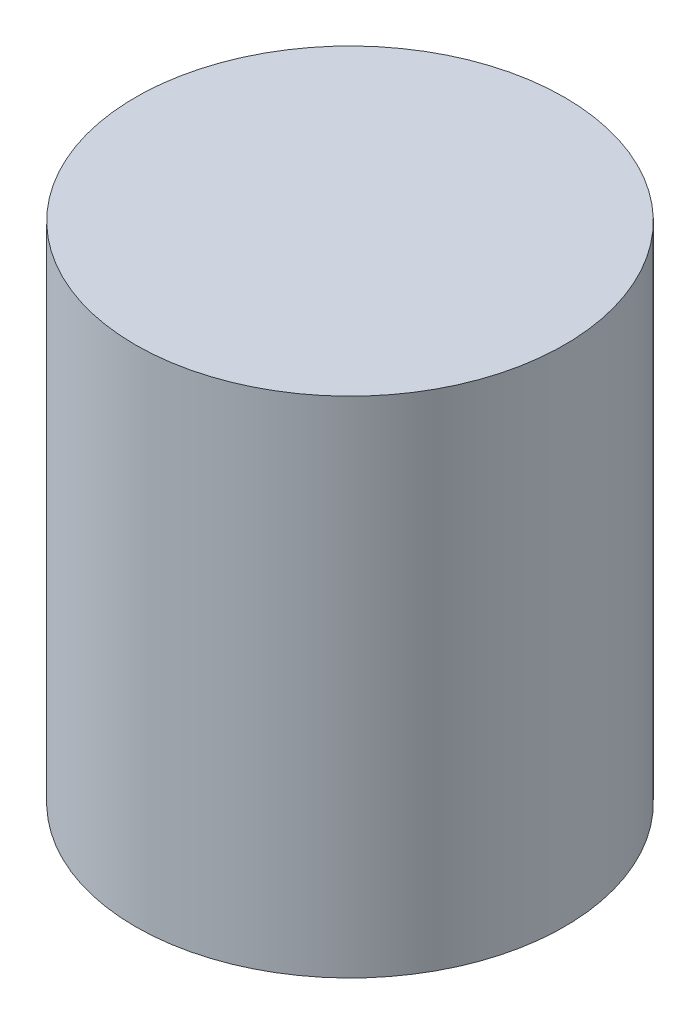
from build123d import *

# Parameters (mm, degrees)
CROQUIS1_R                 = 63
SALIENTE_EXTRUIR1_DEPTH    = 145
CROQUIS2_R                 = 60
CORTAR_EXTRUIR1_DEPTH      = 2
CORTAR_EXTRUIR1_DEPTH_BACK = 142
CROQUIS3_R                 = 63
SALIENTE_EXTRUIR2_DEPTH    = 3


with BuildPart() as part:
    # Croquis1 → Saliente-Extruir1 (new body)
    with BuildSketch(Plane(origin=(0, 0, 0), x_dir=(1, 0, 0), z_dir=(0, 1, 0))):
        Circle(CROQUIS1_R)
    extrude(amount=SALIENTE_EXTRUIR1_DEPTH)

    # Croquis2 → Cortar-Extruir1 (cut, two sides)
    with BuildSketch(Plane(origin=(0, 145, 0), x_dir=(1, 0, 0), z_dir=(0, 1, 0))) as cortar_extruir1_sk:
        Circle(CROQUIS2_R)
    extrude(amount=CORTAR_EXTRUIR1_DEPTH, mode=Mode.SUBTRACT)
    extrude(cortar_extruir1_sk.sketch, amount=-CORTAR_EXTRUIR1_DEPTH_BACK, mode=Mode.SUBTRACT)

    # Croquis3 → Saliente-Extruir2 (add)
    with BuildSketch(Plane(origin=(0, 145, 0), x_dir=(1, 0, 0), z_dir=(0, 1, 0))):
        Circle(CROQUIS3_R)
    extrude(amount=SALIENTE_EXTRUIR2_DEPTH)


solid = part.part
